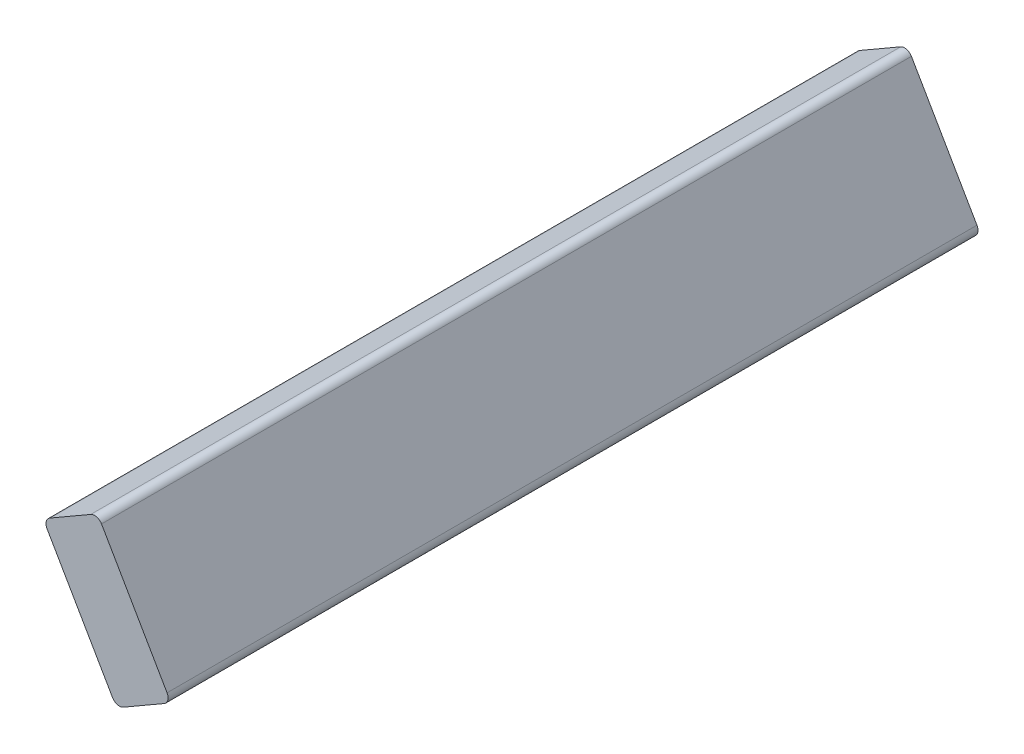
from build123d import *

# Parameters (mm, degrees)
BOSS_EXTRUDE1_DEPTH = 490.537961
FILLET1_R           = 4.7625


with BuildPart() as part:
    # Sketch1 → Boss-Extrude1 (new body)
    with BuildSketch(Plane.XY):
        Polygon((227.693380197, -470.576503047), (183.243380197, -393.586844651), (216.238948081, -374.536844651), (260.688948081, -451.526503047), align=None)
    extrude(amount=BOSS_EXTRUDE1_DEPTH)

    # Fillet1
    fillet1_edges = [part.edges().sort_by_distance(p)[0] for p in [
        (227.693380197, -470.576503047, 245.2689805),
        (183.243380197, -393.586844651, 245.2689805),
        (216.238948081, -374.536844651, 245.2689805),
        (260.688948081, -451.526503047, 245.2689805),
    ]]
    fillet(fillet1_edges, radius=FILLET1_R)


solid = part.part
